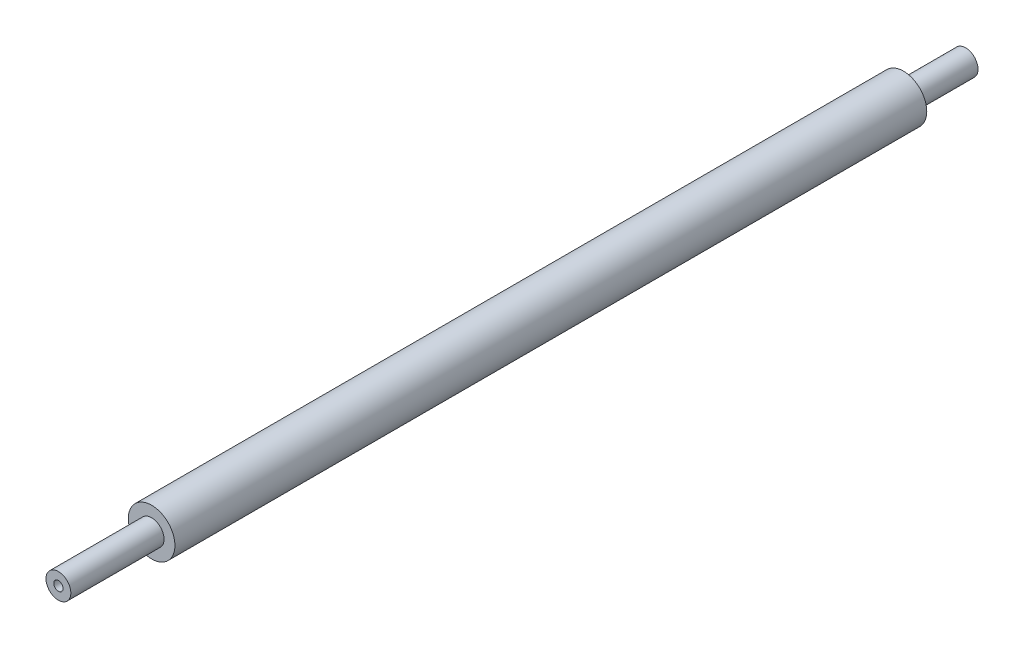
from build123d import *

# Parameters (mm, degrees)
SKETCH1_R           = 7.5
BOSS_EXTRUDE1_DEPTH = 242
SKETCH2_R           = 4
BOSS_EXTRUDE2_DEPTH = 30
SKETCH3_R           = 4
BOSS_EXTRUDE3_DEPTH = 20
SKETCH4_R           = 1.5
CUT_EXTRUDE1_DEPTH  = 8


with BuildPart() as part:
    # Sketch1 → Boss-Extrude1 (new body)
    with BuildSketch(Plane.XY):
        Circle(SKETCH1_R)
    extrude(amount=BOSS_EXTRUDE1_DEPTH)

    # Sketch2 → Boss-Extrude2 (add)
    with BuildSketch(Plane.XY.offset(242)):
        Circle(SKETCH2_R)
    extrude(amount=BOSS_EXTRUDE2_DEPTH)

    # Sketch3 → Boss-Extrude3 (add)
    with BuildSketch(Plane(origin=(0, 0, 0), x_dir=(-1, 0, 0), z_dir=(0, 0, -1))):
        Circle(SKETCH3_R)
    extrude(amount=BOSS_EXTRUDE3_DEPTH)

    # Sketch4 → Cut-Extrude1 (cut)
    with BuildSketch(Plane.XY.offset(272)):
        Circle(SKETCH4_R)
    extrude(amount=-CUT_EXTRUDE1_DEPTH, mode=Mode.SUBTRACT)


solid = part.part
